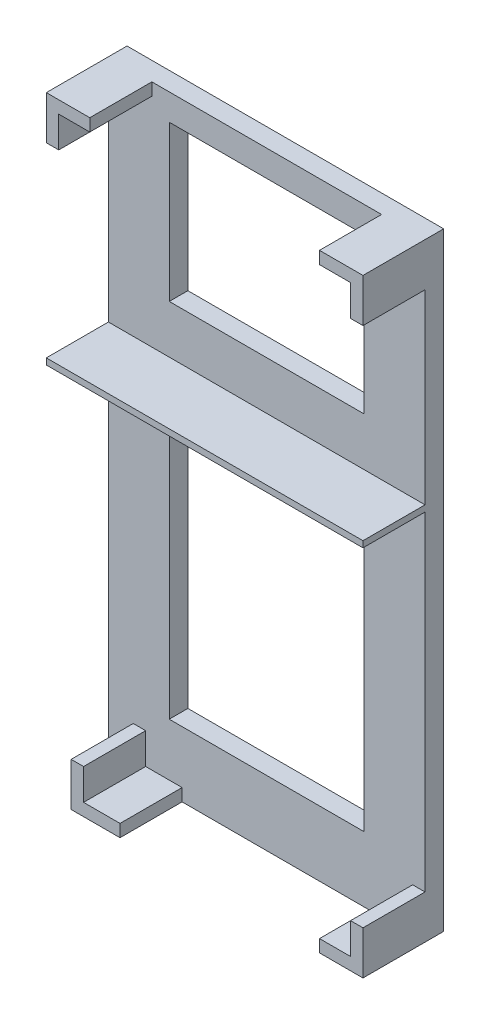
from build123d import *

# Parameters (mm, degrees)
SKETCH1_W           = 51
SKETCH1_H           = 98
BOSS_EXTRUDE2_DEPTH = 3
BOSS_EXTRUDE3_DEPTH = 10
BOSS_EXTRUDE4_DEPTH = 10
SKETCH5_W           = 51
SKETCH5_H           = 1
BOSS_EXTRUDE5_DEPTH = 10
CUT_EXTRUDE1_DEPTH  = 10


with BuildPart() as part:
    # Sketch1 → Boss-Extrude2 (new body)
    with BuildSketch(Plane.XY):
        with Locations((25.5, 49)):
            Rectangle(SKETCH1_W, SKETCH1_H)
    extrude(amount=BOSS_EXTRUDE2_DEPTH)

    # Sketch3 → Boss-Extrude3 (add)
    with BuildSketch(Plane.XY.offset(3)):
        Polygon((0, 98), (7, 98), (7, 96), (2, 96), (2, 91), (0, 91), align=None)
        Polygon((51, 98), (44, 98), (44, 96), (49, 96), (49, 91), (51, 91), align=None)
        Polygon((51, 0), (44, 0), (44, 2), (49, 2), (49, 7), (51, 7), align=None)
    extrude(amount=BOSS_EXTRUDE3_DEPTH)

    # Sketch4 → Boss-Extrude4 (add)
    with BuildSketch(Plane.XY.offset(3)):
        Polygon((4, 0), (4, 7), (6, 7), (6, 2), (11.869482621, 2), (11.869482621, 0), align=None)
    extrude(amount=BOSS_EXTRUDE4_DEPTH)

    # Sketch5 → Boss-Extrude5 (add)
    with BuildSketch(Plane.XY.offset(3)):
        with Locations((25.5, 60.5)):
            Rectangle(SKETCH5_W, SKETCH5_H)
    extrude(amount=BOSS_EXTRUDE5_DEPTH)

    # Sketch6 → Cut-Extrude1 (cut)
    with BuildSketch(Plane.XY.offset(3)):
        Polygon((39.8, 93.770532131), (9.8, 93.770532131), (9.8, 68.770532131), (41.2, 68.770532131), (41.2, 93.770532131), align=None)
        Polygon((39.8, 50.5), (9.8, 50.5), (9.8, 10.5), (41.2, 10.5), (41.2, 50.5), align=None)
    extrude(amount=-CUT_EXTRUDE1_DEPTH, mode=Mode.SUBTRACT)


solid = part.part
